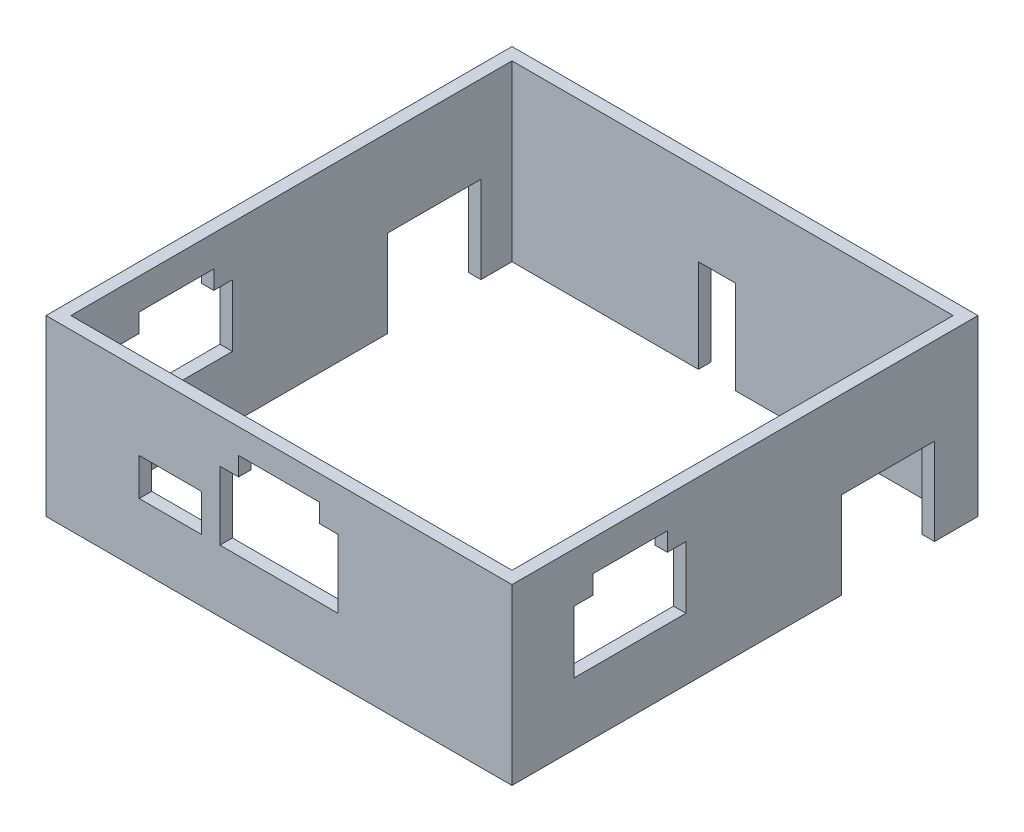
from build123d import *

# Parameters (mm, degrees)
SKETCH1_W           = 75
SKETCH1_H           = 75
BOSS_EXTRUDE1_DEPTH = 28
SKETCH2_W           = 71
SKETCH2_H           = 71
CUT_EXTRUDE1_DEPTH  = 29
SKETCH3_W           = 10
SKETCH3_H           = 6
CUT_EXTRUDE2_DEPTH  = 2
SKETCH4_W           = 15
SKETCH4_H           = 14
CUT_EXTRUDE3_DEPTH  = 76
SKETCH5_W           = 6
SKETCH5_H           = 15
CUT_EXTRUDE4_DEPTH  = 2


with BuildPart() as part:
    # Sketch1 → Boss-Extrude1 (new body)
    with BuildSketch(Plane(origin=(0, 0, 0), x_dir=(1, 0, 0), z_dir=(0, 1, 0))):
        Rectangle(SKETCH1_W, SKETCH1_H)
    extrude(amount=BOSS_EXTRUDE1_DEPTH)

    # Sketch2 → Cut-Extrude1 (cut, through all)
    with BuildSketch(Plane(origin=(0, 28, 0), x_dir=(1, 0, 0), z_dir=(0, 1, 0))):
        Rectangle(SKETCH2_W, SKETCH2_H)
    extrude(amount=-CUT_EXTRUDE1_DEPTH, mode=Mode.SUBTRACT)

    # Sketch3 → Cut-Extrude2 (cut)
    with BuildSketch(Plane.XY.offset(37.5)):
        with Locations((-17.5, 13)):
            Rectangle(SKETCH3_W, SKETCH3_H)
        Polygon((-6.5, 24), (6.5, 24), (6.5, 21), (9.5, 21), (9.5, 10), (-9.5, 10), (-9.5, 21), (-6.5, 21), align=None)
    extrude(amount=-CUT_EXTRUDE2_DEPTH, mode=Mode.SUBTRACT)

    # Sketch4 → Cut-Extrude3 (cut, through all)
    with BuildSketch(Plane.ZY.offset(37.5)):
        Polygon((12.5, 23), (24.5, 23), (24.5, 20), (27.5, 20), (27.5, 10), (9.5, 10), (9.5, 20), (12.5, 20), align=None)
        with Locations((-23, 7)):
            Rectangle(SKETCH4_W, SKETCH4_H)
    extrude(amount=-CUT_EXTRUDE3_DEPTH, mode=Mode.SUBTRACT)

    # Sketch5 → Cut-Extrude4 (cut)
    with BuildSketch(Plane(origin=(0, 0, -37.5), x_dir=(-1, 0, 0), z_dir=(0, 0, -1))):
        with Locations((2.5, 7.5)):
            Rectangle(SKETCH5_W, SKETCH5_H)
    extrude(amount=-CUT_EXTRUDE4_DEPTH, mode=Mode.SUBTRACT)


solid = part.part
